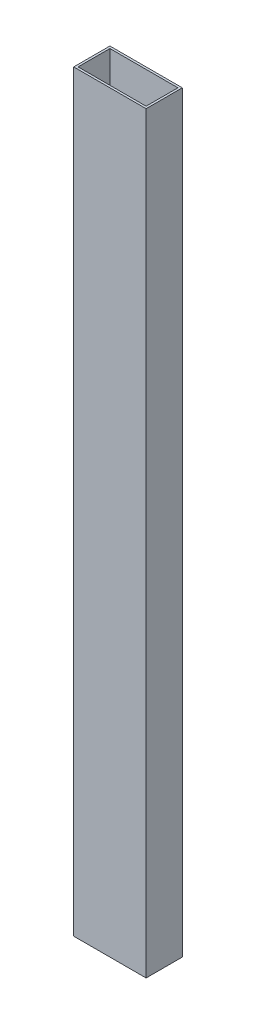
from build123d import *

# Parameters (mm, degrees)
SKETCH1_W           = 50.8
SKETCH1_H           = 25.4
SKETCH1_W_2         = 47.752
SKETCH1_H_2         = 22.352
BOSS_EXTRUDE1_DEPTH = 528.32


with BuildPart() as part:
    # Sketch1 → Boss-Extrude1 (new body)
    with BuildSketch(Plane(origin=(0, 0, 0), x_dir=(1, 0, 0), z_dir=(0, 1, 0))):
        with Locations((16.373230769, 8.069384615)):
            Rectangle(SKETCH1_W, SKETCH1_H)
        with Locations((16.373230769, 8.069384615)):
            Rectangle(SKETCH1_W_2, SKETCH1_H_2, mode=Mode.SUBTRACT)
    extrude(amount=BOSS_EXTRUDE1_DEPTH)


solid = part.part
